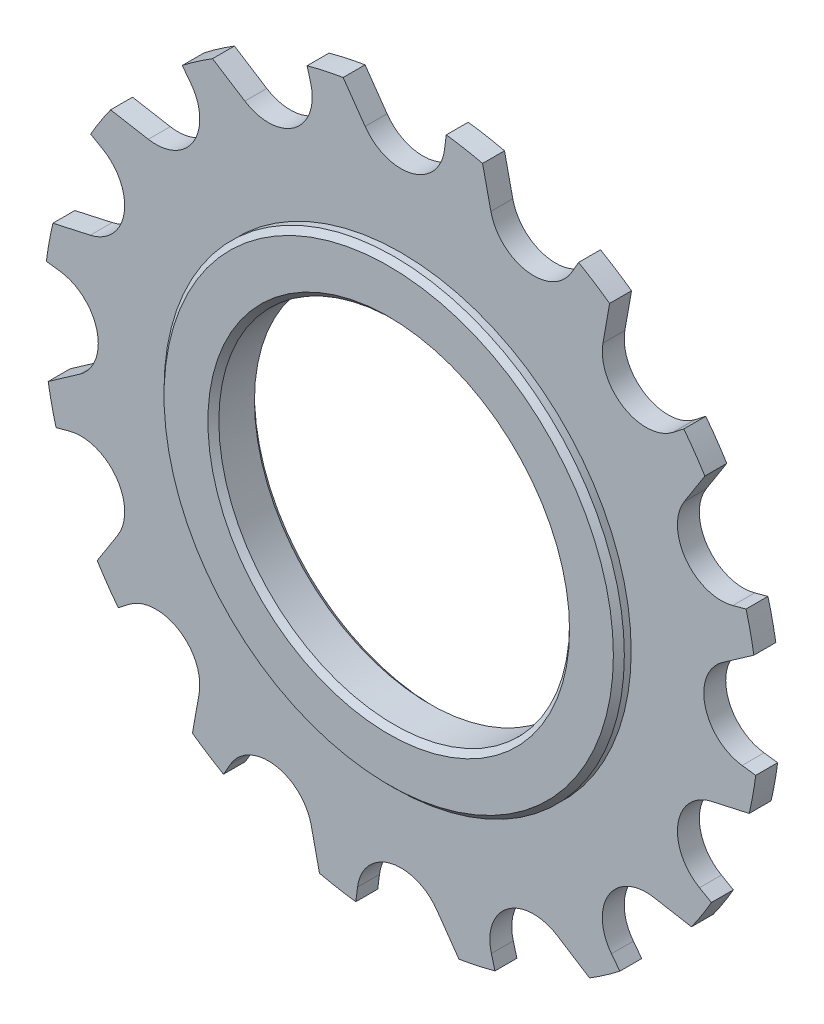
from build123d import *

# Parameters (mm, degrees)
ESQUISSE1_R                  = 32.625
EXTRUSION1_DEPTH             = 1
ENL_V_MAT_EXTRU_1_DEPTH      = 2
R_P_TITION_CIRCULAIRE1_COUNT = 16
ESQUISSE3_R                  = 21
EXTRUSION2_DEPTH             = 2.125
ESQUISSE4_R                  = 16
ENL_V_MAT_EXTRU_2_DEPTH      = 3.125
ENL_V_MAT_EXTRU_2_DEPTH_BACK = 3.125
CHANFREIN1_SIZE              = 0.5


with BuildPart() as part:
    # Esquisse1 → Extrusion1 (new body, symmetric)
    with BuildSketch(Plane.XY):
        Circle(ESQUISSE1_R)
    extrude(amount=EXTRUSION1_DEPTH, both=True)

    # Esquisse2 → Enlèv. mat.-Extru.1 (cut, symmetric)
    with BuildSketch(Plane.XY):
        with BuildLine():
            Line((-5.281931711, 32.194593062), (-3.276608177, 29.330694255))
            ThreePointArc((-3.276608177, 29.330694255), (0.958663447, 27.741578262), (3.967875501, 31.119071146))
            Line((3.967875501, 31.119071146), (4.126482213, 32.362984559))
            ThreePointArc((4.126482213, 32.362984559), (-0.583827722, 32.619775753), (-5.281931711, 32.194593062))
        make_face()
    enl_v_mat_extru_1 = extrude(amount=ENL_V_MAT_EXTRU_1_DEPTH, both=True, mode=Mode.SUBTRACT)

    # Répétition circulaire1: Enlèv. mat.-Extru.1 ×16 about axis
    r_p_tition_circulaire1_axis = Axis((0, 0, 0), (0, 0, 1))
    for i in range(1, R_P_TITION_CIRCULAIRE1_COUNT):
        add(enl_v_mat_extru_1.rotate(r_p_tition_circulaire1_axis, i * 360 / R_P_TITION_CIRCULAIRE1_COUNT), mode=Mode.SUBTRACT)

    # Esquisse3 → Extrusion2 (add, symmetric)
    with BuildSketch(Plane.XY):
        Circle(ESQUISSE3_R)
    extrude(amount=EXTRUSION2_DEPTH, both=True)

    # Esquisse4 → Enlèv. mat.-Extru.2 (cut, two sides)
    with BuildSketch(Plane.XY) as enl_v_mat_extru_2_sk:
        Circle(ESQUISSE4_R)
    extrude(amount=ENL_V_MAT_EXTRU_2_DEPTH, mode=Mode.SUBTRACT)
    extrude(enl_v_mat_extru_2_sk.sketch, amount=-ENL_V_MAT_EXTRU_2_DEPTH_BACK, mode=Mode.SUBTRACT)

    # Chanfrein1
    chanfrein1_edges = [part.edges().sort_by_distance(p)[0] for p in [
        (-21, 0, -2.125),
        (-21, 0, 2.125),
        (-16, 0, -2.125),
        (-16, 0, 2.125),
    ]]
    chamfer(chanfrein1_edges, length=CHANFREIN1_SIZE)


solid = part.part
